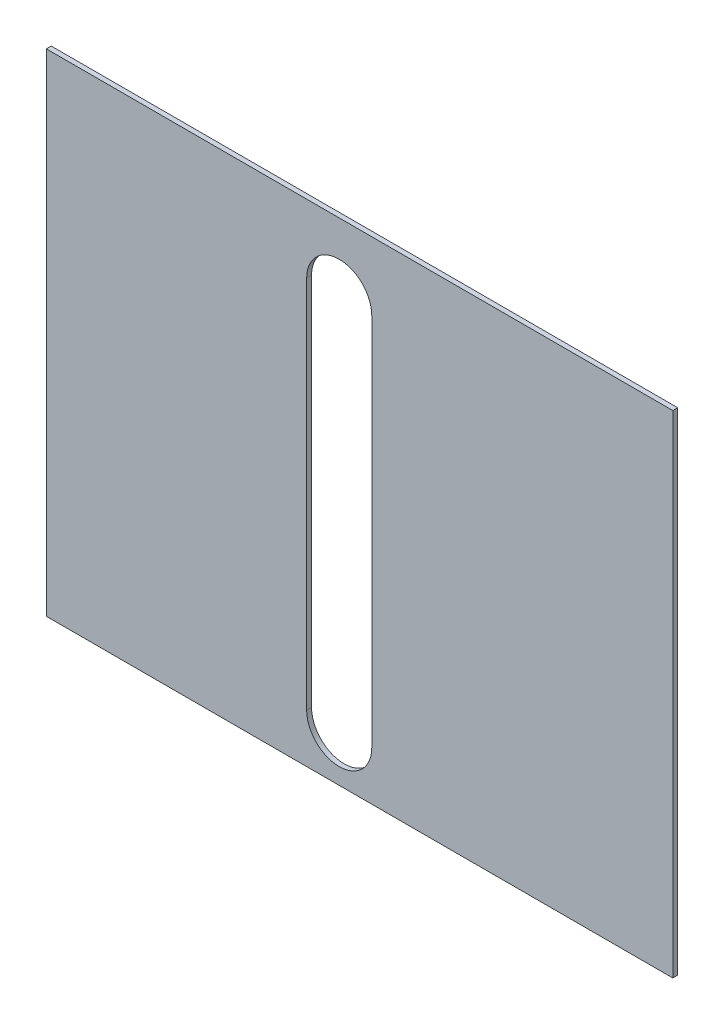
from build123d import *

# Parameters (mm, degrees)
CROQUIS1_W              = 385
CROQUIS1_H              = 302
SALIENTE_EXTRUIR1_DEPTH = 3


with BuildPart() as part:
    # Croquis1 → Saliente-Extruir1 (new body)
    with BuildSketch(Plane.XY):
        with Locations((192.5, 151)):
            Rectangle(CROQUIS1_W, CROQUIS1_H)
        with BuildLine():
            Line((160, 30), (160, 260))
            ThreePointArc((160, 260), (180, 280), (200, 260))
            Line((200, 260), (200, 30))
            ThreePointArc((200, 30), (180, 10), (160, 30))
        make_face(mode=Mode.SUBTRACT)
    extrude(amount=SALIENTE_EXTRUIR1_DEPTH)


solid = part.part
